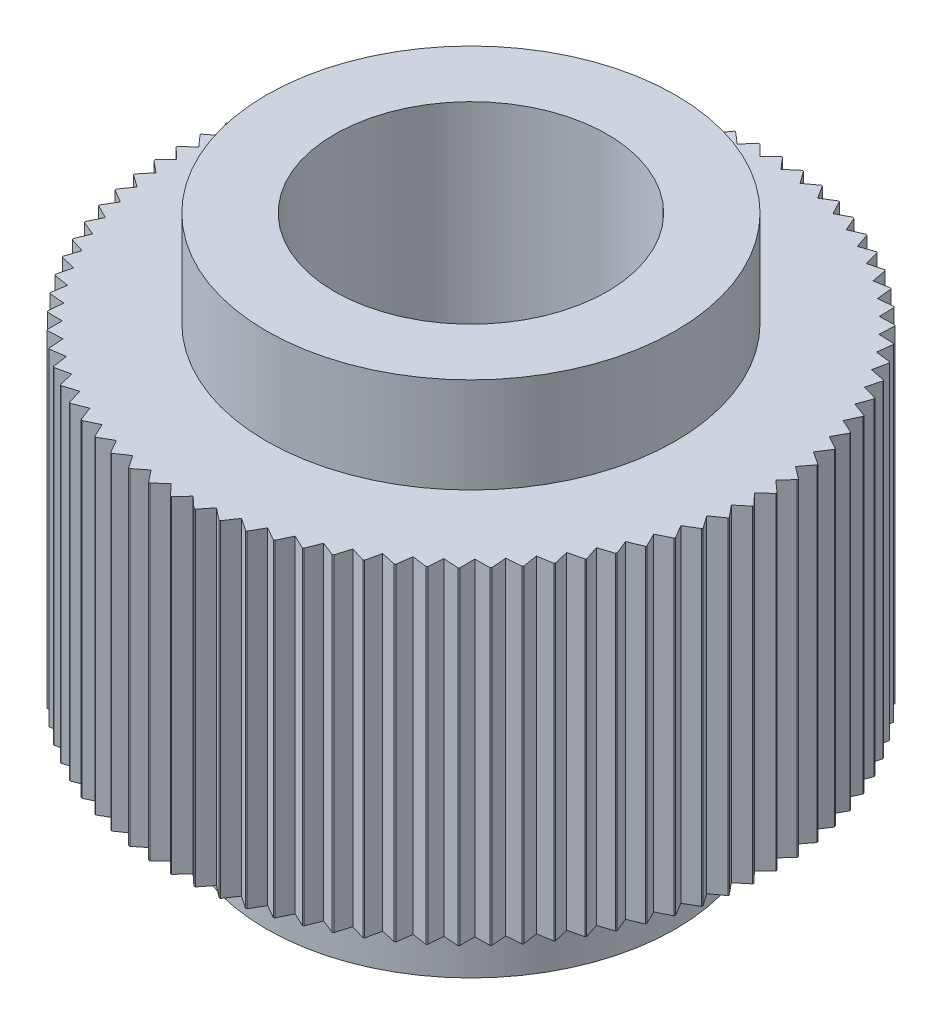
from build123d import *

# Parameters (mm, degrees)
SKETCH_1_R               = 11
EXTRUDE_1_DEPTH          = 12
SKETCH_2_R               = 7.5
EXTRUDE_2_DEPTH          = 3.5
SKETCH_3_R               = 7.5
EXTRUDE_3_DEPTH          = 3.5
SKETCH_4_R               = 5
CUT_EXTRUDE_1_DEPTH      = 20
CUT_EXTRUDE_2_DEPTH      = 16.5
PATTERN_CIRCULAR_1_COUNT = 83


with BuildPart() as part:
    # 草图1 → 凸台-拉伸1 (new body)
    with BuildSketch(Plane(origin=(0, 0, 0), x_dir=(1, 0, 0), z_dir=(0, 1, 0))):
        Circle(SKETCH_1_R)
    extrude(amount=EXTRUDE_1_DEPTH)

    # 草图2 → 凸台-拉伸2 (add)
    with BuildSketch(Plane.XZ):
        Circle(SKETCH_2_R)
    extrude(amount=EXTRUDE_2_DEPTH)

    # 草图3 → 凸台-拉伸3 (add)
    with BuildSketch(Plane(origin=(0, 12, 0), x_dir=(1, 0, 0), z_dir=(0, 1, 0))):
        Circle(SKETCH_3_R)
    extrude(amount=EXTRUDE_3_DEPTH)

    # 草图4 → 切除-拉伸1 (cut, through all)
    with BuildSketch(Plane(origin=(0, 15.5, 0), x_dir=(1, 0, 0), z_dir=(0, 1, 0))):
        Circle(SKETCH_4_R)
    extrude(amount=-CUT_EXTRUDE_1_DEPTH, mode=Mode.SUBTRACT)

    # 草图5 → 切除-拉伸2 (cut, through all)
    with BuildSketch(Plane(origin=(0, 12, 0), x_dir=(1, 0, 0), z_dir=(0, 1, 0))):
        with BuildLine():
            Line((-0.392978131, 10.992978131), (0, 10.6))
            Line((0, 10.6), (0.392978131, 10.992978131))
            ThreePointArc((0.392978131, 10.992978131), (0, 11), (-0.392978131, 10.992978131))
        make_face()
    cut_extrude_2 = extrude(amount=-CUT_EXTRUDE_2_DEPTH, mode=Mode.SUBTRACT)

    # 阵列(圆周)1: 切除-拉伸2 ×83 about axis
    pattern_circular_1_axis = Axis((0, 0, 0), (0, 1, 0))
    for i in range(1, PATTERN_CIRCULAR_1_COUNT):
        add(cut_extrude_2.rotate(pattern_circular_1_axis, i * 360 / PATTERN_CIRCULAR_1_COUNT), mode=Mode.SUBTRACT)


solid = part.part
